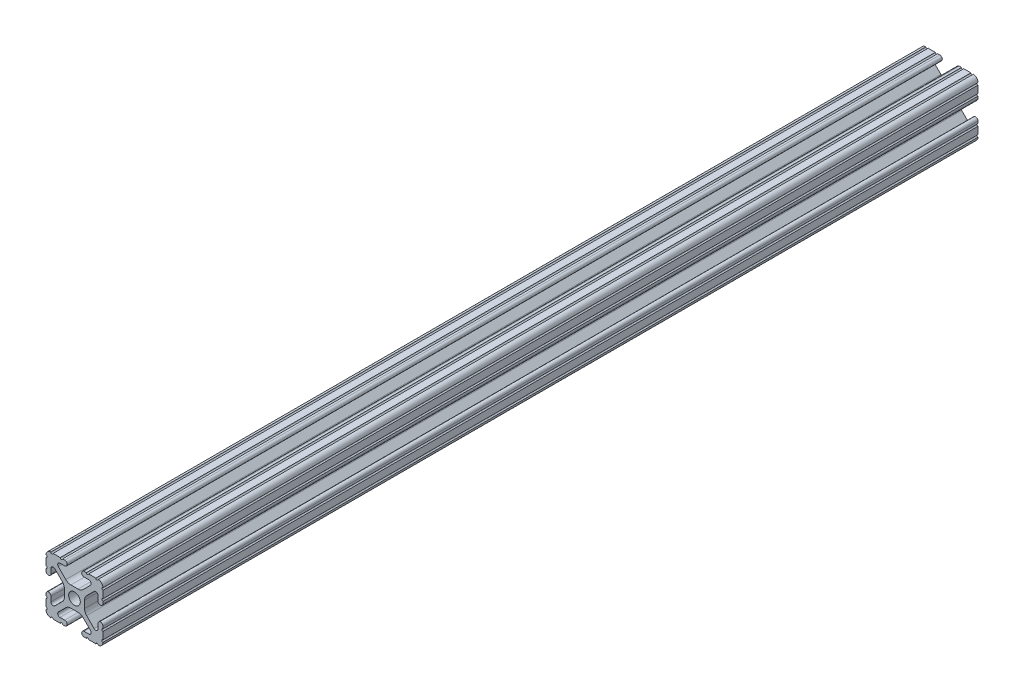
from build123d import *

# Parameters (mm, degrees)
SKETCH1_R           = 2.6035
BOSS_EXTRUDE1_DEPTH = 195.2752


with BuildPart() as part:
    # Sketch1 → Boss-Extrude1 (new body, symmetric)
    with BuildSketch(Plane(origin=(0, 0, -450.85), x_dir=(-1, 0, 0), z_dir=(0, 0, -1))):
        with BuildLine():
            Line((12.7, -9.5504), (12.7, -6.3330836))
            ThreePointArc((12.7, -6.3330836), (12.192, -5.8250836), (12.7, -5.3170836))
            Line((12.7, -5.3170836), (12.7, -4.3434))
            ThreePointArc((12.7, -4.3434), (11.5951, -3.2385), (10.4902, -4.3434))
            Line((10.4902, -4.3434), (10.4902, -6.474794456))
            ThreePointArc((10.4902, -6.474794456), (9.863006367, -7.413456061), (8.75577951, -7.193214945))
            Line((8.75577951, -7.193214945), (5.42573597, -3.863171405))
            ThreePointArc((5.42573597, -3.863171405), (4.737482484, -2.833127272), (4.4958, -1.618107374))
            Line((4.4958, -1.618107374), (4.4958, 1.618107374))
            ThreePointArc((4.4958, 1.618107374), (4.737482484, 2.833127272), (5.42573597, 3.863171405))
            Line((5.42573597, 3.863171405), (8.75577951, 7.193214945))
            ThreePointArc((8.75577951, 7.193214945), (9.863006367, 7.413456061), (10.4902, 6.474794456))
            Line((10.4902, 6.474794456), (10.4902, 4.343399971))
            ThreePointArc((10.4902, 4.343399971), (11.5951, 3.238499971), (12.7, 4.343399971))
            Line((12.7, 4.343399971), (12.7, 5.3170836))
            ThreePointArc((12.7, 5.3170836), (12.192, 5.8250836), (12.7, 6.3330836))
            Line((12.7, 6.3330836), (12.7, 9.5504))
            ThreePointArc((12.7, 9.5504), (12.192000006, 10.058323491), (12.699846982, 10.566399977))
            ThreePointArc((12.699846982, 10.566399977), (12.082522516, 12.082522516), (10.566399977, 12.699846982))
            ThreePointArc((10.566399977, 12.699846982), (10.058323491, 12.192000006), (9.5504, 12.7))
            Line((9.5504, 12.7), (6.3330836, 12.7))
            ThreePointArc((6.3330836, 12.7), (5.8250836, 12.192), (5.3170836, 12.7))
            Line((5.3170836, 12.7), (4.3434, 12.7))
            ThreePointArc((4.3434, 12.7), (3.2385, 11.5951), (4.3434, 10.4902))
            Line((4.3434, 10.4902), (6.474794456, 10.4902))
            ThreePointArc((6.474794456, 10.4902), (7.413456061, 9.863006367), (7.193214945, 8.75577951))
            Line((7.193214945, 8.75577951), (3.863171405, 5.42573597))
            ThreePointArc((3.863171405, 5.42573597), (2.833127272, 4.737482484), (1.618107374, 4.4958))
            Line((1.618107374, 4.4958), (-1.618107374, 4.4958))
            ThreePointArc((-1.618107374, 4.4958), (-2.833127272, 4.737482484), (-3.863171405, 5.42573597))
            Line((-3.863171405, 5.42573597), (-7.193214945, 8.75577951))
            ThreePointArc((-7.193214945, 8.75577951), (-7.413456061, 9.863006367), (-6.474794456, 10.4902))
            Line((-6.474794456, 10.4902), (-4.343399971, 10.4902))
            ThreePointArc((-4.343399971, 10.4902), (-3.238499971, 11.5951), (-4.343399971, 12.7))
            Line((-4.343399971, 12.7), (-5.3170836, 12.7))
            ThreePointArc((-5.3170836, 12.7), (-5.8250836, 12.192), (-6.3330836, 12.7))
            Line((-6.3330836, 12.7), (-9.5504, 12.7))
            ThreePointArc((-9.5504, 12.7), (-10.058323491, 12.192000006), (-10.566399977, 12.699846982))
            ThreePointArc((-10.566399977, 12.699846982), (-12.082522516, 12.082522516), (-12.699846982, 10.566399977))
            ThreePointArc((-12.699846982, 10.566399977), (-12.192000006, 10.058323491), (-12.7, 9.5504))
            Line((-12.7, 9.5504), (-12.7, 6.3330836))
            ThreePointArc((-12.7, 6.3330836), (-12.192, 5.8250836), (-12.7, 5.3170836))
            Line((-12.7, 5.3170836), (-12.7, 4.3434))
            ThreePointArc((-12.7, 4.3434), (-11.5951, 3.2385), (-10.4902, 4.3434))
            Line((-10.4902, 4.3434), (-10.4902, 6.474794456))
            ThreePointArc((-10.4902, 6.474794456), (-9.863006367, 7.413456061), (-8.75577951, 7.193214945))
            Line((-8.75577951, 7.193214945), (-5.42573597, 3.863171405))
            ThreePointArc((-5.42573597, 3.863171405), (-4.737482484, 2.833127272), (-4.4958, 1.618107374))
            Line((-4.4958, 1.618107374), (-4.4958, -1.618107374))
            ThreePointArc((-4.4958, -1.618107374), (-4.737482484, -2.833127272), (-5.42573597, -3.863171405))
            Line((-5.42573597, -3.863171405), (-8.75577951, -7.193214945))
            ThreePointArc((-8.75577951, -7.193214945), (-9.863006367, -7.413456061), (-10.4902, -6.474794456))
            Line((-10.4902, -6.474794456), (-10.4902, -4.343399971))
            ThreePointArc((-10.4902, -4.343399971), (-11.5951, -3.238499971), (-12.7, -4.343399971))
            Line((-12.7, -4.343399971), (-12.7, -5.3170836))
            ThreePointArc((-12.7, -5.3170836), (-12.192, -5.8250836), (-12.7, -6.3330836))
            Line((-12.7, -6.3330836), (-12.7, -9.5504))
            ThreePointArc((-12.7, -9.5504), (-12.192000006, -10.058323491), (-12.699846982, -10.566399977))
            ThreePointArc((-12.699846982, -10.566399977), (-12.082522516, -12.082522516), (-10.566399977, -12.699846982))
            ThreePointArc((-10.566399977, -12.699846982), (-10.058323491, -12.192000006), (-9.5504, -12.7))
            Line((-9.5504, -12.7), (-6.3330836, -12.7))
            ThreePointArc((-6.3330836, -12.7), (-5.8250836, -12.192), (-5.3170836, -12.7))
            Line((-5.3170836, -12.7), (-4.3434, -12.7))
            ThreePointArc((-4.3434, -12.7), (-3.2385, -11.5951), (-4.3434, -10.4902))
            Line((-4.3434, -10.4902), (-6.474794456, -10.4902))
            ThreePointArc((-6.474794456, -10.4902), (-7.413456061, -9.863006367), (-7.193214945, -8.75577951))
            Line((-7.193214945, -8.75577951), (-3.863171405, -5.42573597))
            ThreePointArc((-3.863171405, -5.42573597), (-2.833127272, -4.737482484), (-1.618107374, -4.4958))
            Line((-1.618107374, -4.4958), (1.618107374, -4.4958))
            ThreePointArc((1.618107374, -4.4958), (2.833127272, -4.737482484), (3.863171405, -5.42573597))
            Line((3.863171405, -5.42573597), (7.193214945, -8.75577951))
            ThreePointArc((7.193214945, -8.75577951), (7.413456061, -9.863006367), (6.474794456, -10.4902))
            Line((6.474794456, -10.4902), (4.343399971, -10.4902))
            ThreePointArc((4.343399971, -10.4902), (3.238499971, -11.5951), (4.343399971, -12.7))
            Line((4.343399971, -12.7), (5.3170836, -12.7))
            ThreePointArc((5.3170836, -12.7), (5.8250836, -12.192), (6.3330836, -12.7))
            Line((6.3330836, -12.7), (9.5504, -12.7))
            ThreePointArc((9.5504, -12.7), (10.058323491, -12.192000006), (10.566399977, -12.699846982))
            ThreePointArc((10.566399977, -12.699846982), (12.082522516, -12.082522516), (12.699846982, -10.566399977))
            ThreePointArc((12.699846982, -10.566399977), (12.192000006, -10.058323491), (12.7, -9.5504))
        make_face()
        Circle(SKETCH1_R, mode=Mode.SUBTRACT)
    extrude(amount=BOSS_EXTRUDE1_DEPTH, both=True)


solid = part.part
